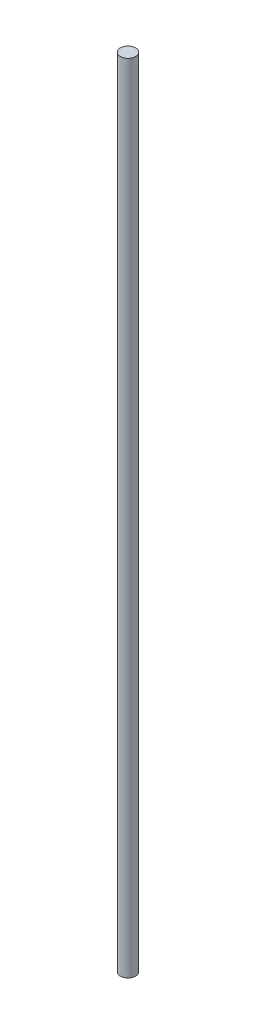
from build123d import *

# Parameters (mm, degrees)
SKETCH1_R           = 4
BOSS_EXTRUDE1_DEPTH = 420


with BuildPart() as part:
    # Sketch1 → Boss-Extrude1 (new body)
    with BuildSketch(Plane(origin=(0, 0, 0), x_dir=(1, 0, 0), z_dir=(0, 1, 0))):
        Circle(SKETCH1_R)
    extrude(amount=BOSS_EXTRUDE1_DEPTH)


solid = part.part
